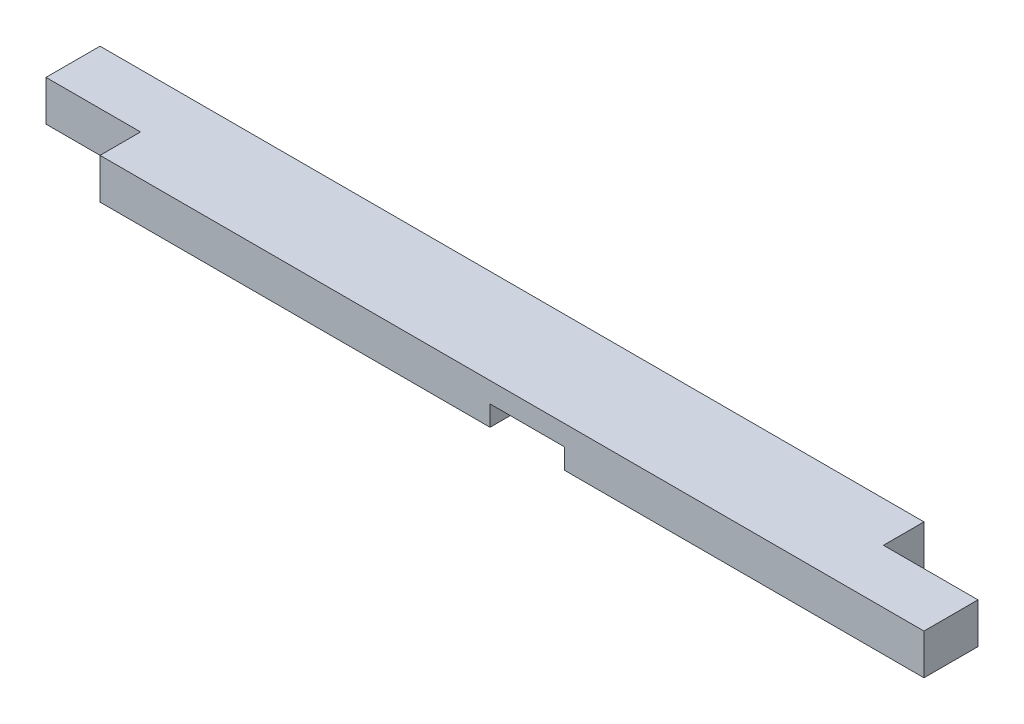
from build123d import *

# Parameters (mm, degrees)
SKETCH1_W           = 863.6
SKETCH1_H           = 88.9
BOSS_EXTRUDE1_DEPTH = 38.1
SKETCH3_W           = 88.9
SKETCH3_H           = 38.1
CUT_EXTRUDE2_DEPTH  = 39.1
SKETCH4_W           = 69.85
SKETCH4_H           = 19.05
CUT_EXTRUDE3_DEPTH  = 89.9
SKETCH5_W           = 88.9
SKETCH5_H           = 38.1
CUT_EXTRUDE4_DEPTH  = 39.1


with BuildPart() as part:
    # Sketch1 → Boss-Extrude1 (new body)
    with BuildSketch(Plane(origin=(0, 0, 0), x_dir=(1, 0, 0), z_dir=(0, 1, 0))):
        with Locations((431.8, 44.45)):
            Rectangle(SKETCH1_W, SKETCH1_H)
    extrude(amount=BOSS_EXTRUDE1_DEPTH)

    # Sketch3 → Cut-Extrude2 (cut, through all)
    with BuildSketch(Plane(origin=(0, 38.1, 0), x_dir=(1, 0, 0), z_dir=(0, 1, 0))):
        with Locations((819.15, 69.85)):
            Rectangle(SKETCH3_W, SKETCH3_H)
    extrude(amount=-CUT_EXTRUDE2_DEPTH, mode=Mode.SUBTRACT)

    # Sketch4 → Cut-Extrude3 (cut, through all)
    with BuildSketch(Plane(origin=(0, 0, -88.9), x_dir=(-1, 0, 0), z_dir=(0, 0, -1))):
        with Locations((-490.5375, 9.525)):
            Rectangle(SKETCH4_W, SKETCH4_H)
    extrude(amount=-CUT_EXTRUDE3_DEPTH, mode=Mode.SUBTRACT)

    # Sketch5 → Cut-Extrude4 (cut, through all)
    with BuildSketch(Plane.XZ):
        with Locations((44.45, -19.05)):
            Rectangle(SKETCH5_W, SKETCH5_H)
    extrude(amount=-CUT_EXTRUDE4_DEPTH, mode=Mode.SUBTRACT)


solid = part.part
